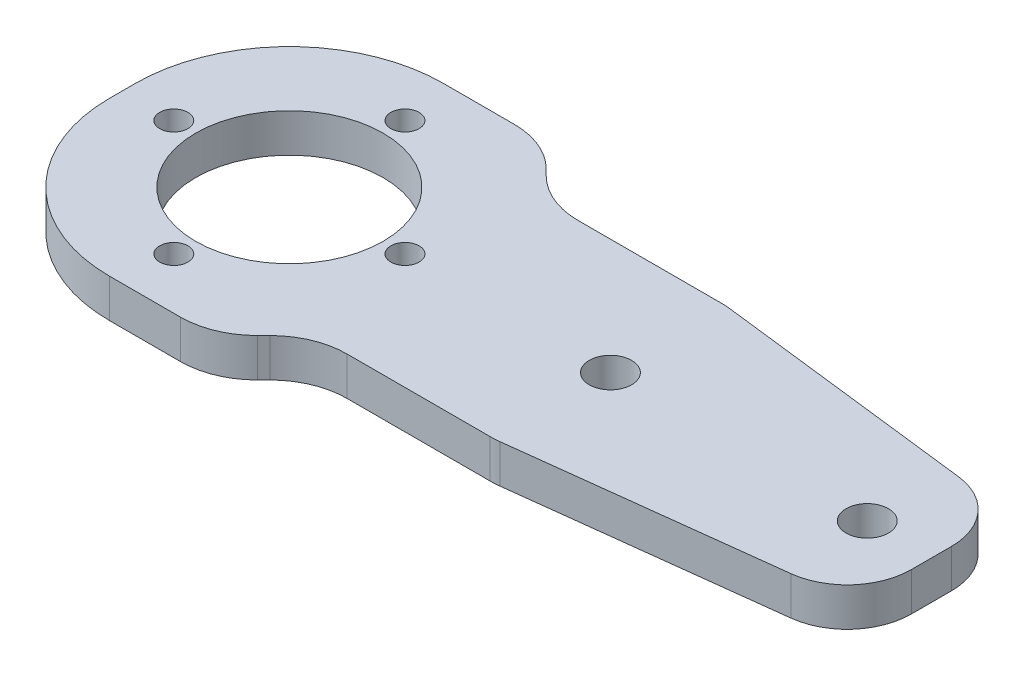
from build123d import *

# Parameters (mm, degrees)
SKETCH1_R           = 7.3
SKETCH1_R_2         = 1.65
BOSS_EXTRUDE1_DEPTH = 3
FILLET1_R           = 12
FILLET4_R           = 6
FILLET5_R           = 5
SKETCH2_R           = 1.1
CUT_EXTRUDE1_DEPTH  = 10


with BuildPart() as part:
    # Sketch1 → Boss-Extrude1 (new body)
    with BuildSketch(Plane(origin=(0, 0, 0), x_dir=(1, 0, 0), z_dir=(0, 1, 0))):
        Polygon((20, 26), (24, 22), (38, 22), (63, 19), (63, 7), (38, 4), (24, 4), (20, 0), (0, 0), (0, 26), align=None)
        with Locations((13, 13)):
            Circle(SKETCH1_R, mode=Mode.SUBTRACT)
        with Locations((38, 13)):
            Circle(SKETCH1_R_2, mode=Mode.SUBTRACT)
        with Locations((58, 13)):
            Circle(SKETCH1_R_2, mode=Mode.SUBTRACT)
    extrude(amount=BOSS_EXTRUDE1_DEPTH)

    # Fillet1
    fillet1_edges = [part.edges().sort_by_distance(p)[0] for p in [
        (0, 1.5, 0),
        (0, 1.5, -26),
    ]]
    fillet(fillet1_edges, radius=FILLET1_R)

    # Fillet4
    fillet4_edges = [part.edges().sort_by_distance(p)[0] for p in [
        (20, 1.5, -26),
        (24, 1.5, -22),
        (38, 1.5, -22),
        (38, 1.5, -4),
        (24, 1.5, -4),
        (20, 1.5, 0),
    ]]
    fillet(fillet4_edges, radius=FILLET4_R)

    # Fillet5
    fillet5_edges = [part.edges().sort_by_distance(p)[0] for p in [
        (63, 1.5, -19),
        (63, 1.5, -7),
    ]]
    fillet(fillet5_edges, radius=FILLET5_R)

    # Sketch2 → Cut-Extrude1 (cut)
    with BuildSketch(Plane(origin=(0, 3, 0), x_dir=(1, 0, 0), z_dir=(0, 1, 0))):
        with Locations((22, 13)):
            Circle(SKETCH2_R)
        with Locations((13, 4)):
            Circle(SKETCH2_R)
        with Locations((4, 13)):
            Circle(SKETCH2_R)
        with Locations((13, 22)):
            Circle(SKETCH2_R)
    extrude(amount=-CUT_EXTRUDE1_DEPTH, mode=Mode.SUBTRACT)


solid = part.part
